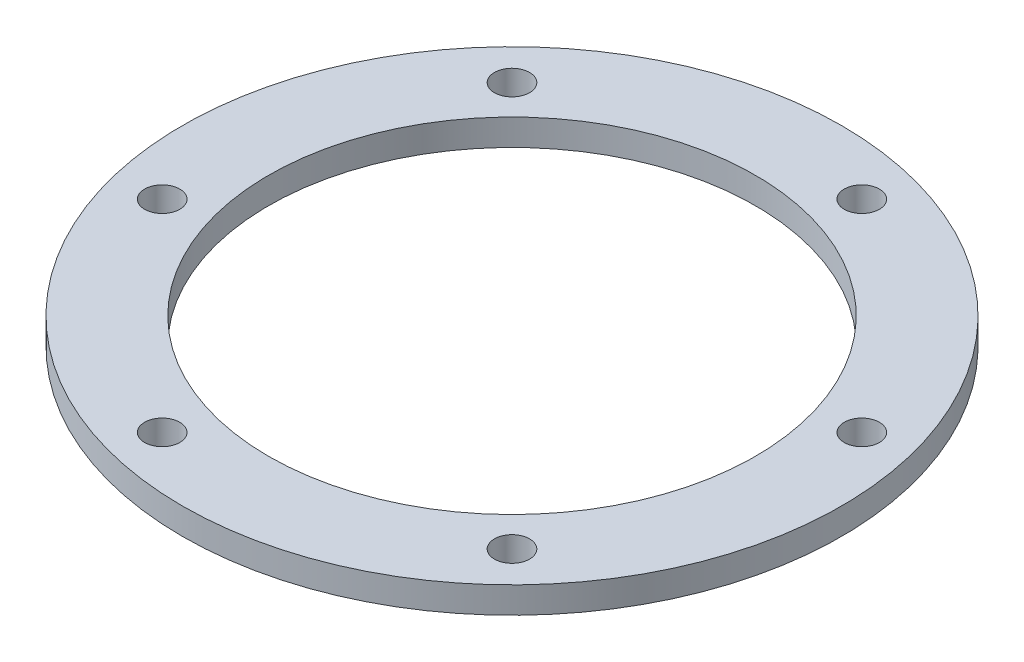
from build123d import *

# Parameters (mm, degrees)
SKETCH1_R           = 37.5
SKETCH1_R_2         = 27.7
SKETCH1_R_3         = 2
BOSS_EXTRUDE1_DEPTH = 3


with BuildPart() as part:
    # Sketch1 → Boss-Extrude1 (new body)
    with BuildSketch(Plane(origin=(0, 0, 0), x_dir=(1, 0, 0), z_dir=(0, 1, 0))):
        Circle(SKETCH1_R)
        Circle(SKETCH1_R_2, mode=Mode.SUBTRACT)
        with Locations((22.980970389, -22.980970389)):
            Circle(SKETCH1_R_3, mode=Mode.SUBTRACT)
        with Locations((-8.411618966, -31.392589354)):
            Circle(SKETCH1_R_3, mode=Mode.SUBTRACT)
        with Locations((-31.392589354, -8.411618966)):
            Circle(SKETCH1_R_3, mode=Mode.SUBTRACT)
        with Locations((-22.980970389, 22.980970389)):
            Circle(SKETCH1_R_3, mode=Mode.SUBTRACT)
        with Locations((8.411618966, 31.392589354)):
            Circle(SKETCH1_R_3, mode=Mode.SUBTRACT)
        with Locations((31.392589354, 8.411618966)):
            Circle(SKETCH1_R_3, mode=Mode.SUBTRACT)
    extrude(amount=BOSS_EXTRUDE1_DEPTH)


solid = part.part
